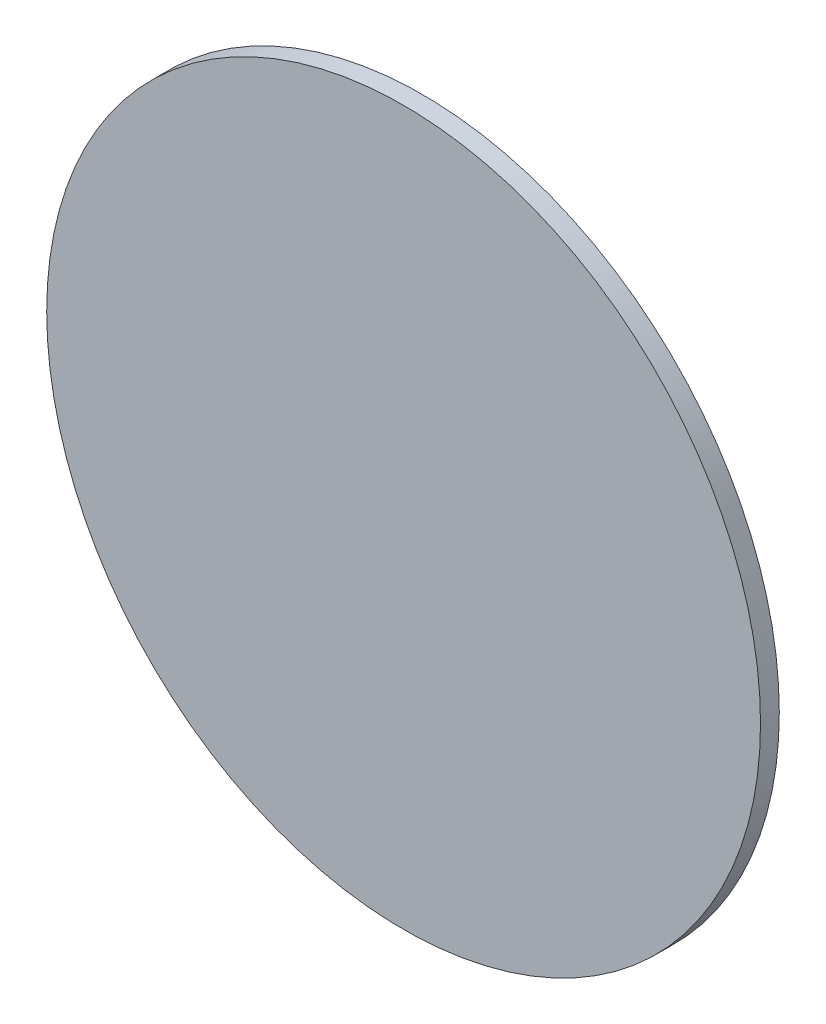
from build123d import *

# Parameters (mm, degrees)
CROQUIS2_R              = 19
SALIENTE_EXTRUIR1_DEPTH = 1


with BuildPart() as part:
    # Croquis2 → Saliente-Extruir1 (new body)
    with BuildSketch(Plane.XY):
        Circle(CROQUIS2_R)
    extrude(amount=SALIENTE_EXTRUIR1_DEPTH)


solid = part.part
